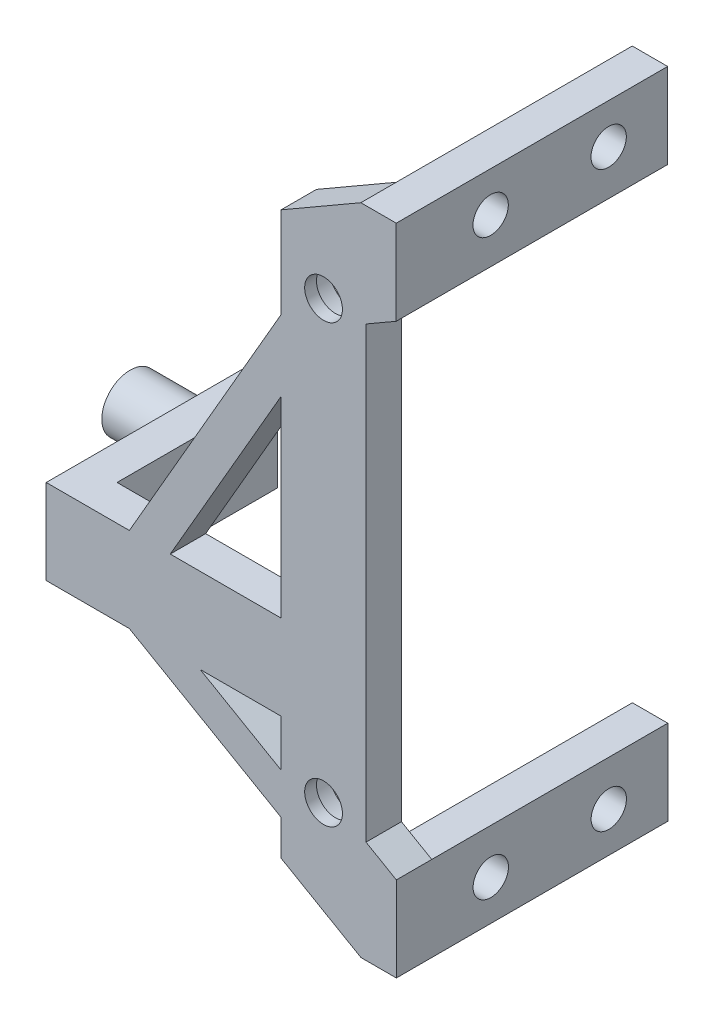
from build123d import *

# Parameters (mm, degrees)
SKETCH1_R           = 1.6
BOSS_EXTRUDE1_DEPTH = 3
SKETCH2_R           = 2.75
CUT_EXTRUDE1_DEPTH  = 2
SKETCH4_W           = 3
SKETCH4_H           = 7.2
BOSS_EXTRUDE2_DEPTH = 20
CUT_EXTRUDE2_REACH  = 5.01
SKETCH5_R           = 1.4975
SKETCH7_W           = 13.6
SKETCH7_H           = 7.2
BOSS_EXTRUDE3_DEPTH = 3
SKETCH8_R           = 2.4
BOSS_EXTRUDE4_DEPTH = 5.89


with BuildPart() as part:
    # Sketch1 → Boss-Extrude1 (new body)
    with BuildSketch(Plane.XY):
        Polygon((3.6, 18.431983311), (3.6, -19.596209808), (6.17, -21.08), (6.17, -28.28), (3.17, -28.28), (-3.6, -24.371338678), (-3.6, -21.371338678), (-16.45413565, -13.95), (-20.5, -13.95), (-23.5, -13.95), (-23.5, -6.75), (-20.5, -6.75), (-16.45413565, -6.75), (-3.6, 15.514016033), (-3.6, 23.20711218), (3.16, 27.11), (6.16, 27.11), (6.16, 19.91), align=None)
        with Locations((0, 18.5)):
            Circle(SKETCH1_R, mode=Mode.SUBTRACT)
        with Locations((0, -18.5)):
            Circle(SKETCH1_R, mode=Mode.SUBTRACT)
        Polygon((-10.45413565, -13.95), (-3.6, -13.95), (-3.6, -17.907237062), align=None, mode=Mode.SUBTRACT)
        Polygon((-3.6, -6.75), (-12.990034035, -6.75), (-3.6, 9.514016033), align=None, mode=Mode.SUBTRACT)
    extrude(amount=BOSS_EXTRUDE1_DEPTH)

    # Sketch2 → Cut-Extrude1 (cut)
    with BuildSketch(Plane(origin=(0, 0, 0), x_dir=(-1, 0, 0), z_dir=(0, 0, -1))):
        with Locations((0, 18.5)):
            Circle(SKETCH2_R)
        with Locations((0, -18.5)):
            Circle(SKETCH2_R)
    extrude(amount=-CUT_EXTRUDE1_DEPTH, mode=Mode.SUBTRACT)

    # Sketch4 → Boss-Extrude2 (add)
    with BuildSketch(Plane(origin=(0, 0, 0), x_dir=(-1, 0, 0), z_dir=(0, 0, -1))):
        with Locations((-4.66, 23.51)):
            Rectangle(SKETCH4_W, SKETCH4_H)
        with Locations((-4.67, -24.68)):
            Rectangle(SKETCH4_W, SKETCH4_H)
    extrude(amount=BOSS_EXTRUDE2_DEPTH)

    # Sketch5 → Cut-Extrude2 (cut, up to next)
    with BuildSketch(Plane.ZY.offset(-3.16), mode=Mode.PRIVATE) as cut_extrude2_sk1:
        with Locations((-5, 23.71)):
            Circle(SKETCH5_R)
    cut_extrude2_tool1 = extrude(cut_extrude2_sk1.sketch, amount=-CUT_EXTRUDE2_REACH, mode=Mode.PRIVATE) & part.part
    add(cut_extrude2_tool1.solids().sort_by_distance((3.16, 23.71, -5))[0], mode=Mode.SUBTRACT)
    # Sketch5 → Cut-Extrude2 (cut, up to next)
    with BuildSketch(Plane.ZY.offset(-3.16), mode=Mode.PRIVATE) as cut_extrude2_sk2:
        with Locations((-15, 23.71)):
            Circle(SKETCH5_R)
    cut_extrude2_tool2 = extrude(cut_extrude2_sk2.sketch, amount=-CUT_EXTRUDE2_REACH, mode=Mode.PRIVATE) & part.part
    add(cut_extrude2_tool2.solids().sort_by_distance((3.16, 23.71, -15))[0], mode=Mode.SUBTRACT)
    # Sketch5 → Cut-Extrude2 (cut, up to next)
    with BuildSketch(Plane.ZY.offset(-3.16), mode=Mode.PRIVATE) as cut_extrude2_sk3:
        with Locations((-15, -24.88)):
            Circle(SKETCH5_R)
    cut_extrude2_tool3 = extrude(cut_extrude2_sk3.sketch, amount=-CUT_EXTRUDE2_REACH, mode=Mode.PRIVATE) & part.part
    add(cut_extrude2_tool3.solids().sort_by_distance((3.16, -24.88, -15))[0], mode=Mode.SUBTRACT)
    # Sketch5 → Cut-Extrude2 (cut, up to next)
    with BuildSketch(Plane.ZY.offset(-3.16), mode=Mode.PRIVATE) as cut_extrude2_sk4:
        with Locations((-5, -24.88)):
            Circle(SKETCH5_R)
    cut_extrude2_tool4 = extrude(cut_extrude2_sk4.sketch, amount=-CUT_EXTRUDE2_REACH, mode=Mode.PRIVATE) & part.part
    add(cut_extrude2_tool4.solids().sort_by_distance((3.16, -24.88, -5))[0], mode=Mode.SUBTRACT)

    # Sketch7 → Boss-Extrude3 (add)
    with BuildSketch(Plane.ZY.offset(23.5)):
        with Locations((-6.8, -10.35)):
            Rectangle(SKETCH7_W, SKETCH7_H)
    extrude(amount=-BOSS_EXTRUDE3_DEPTH)

    # Sketch8 → Boss-Extrude4 (add)
    with BuildSketch(Plane.ZY.offset(23.5)):
        with Locations((-10, -10.35)):
            Circle(SKETCH8_R)
    extrude(amount=BOSS_EXTRUDE4_DEPTH)


solid = part.part
